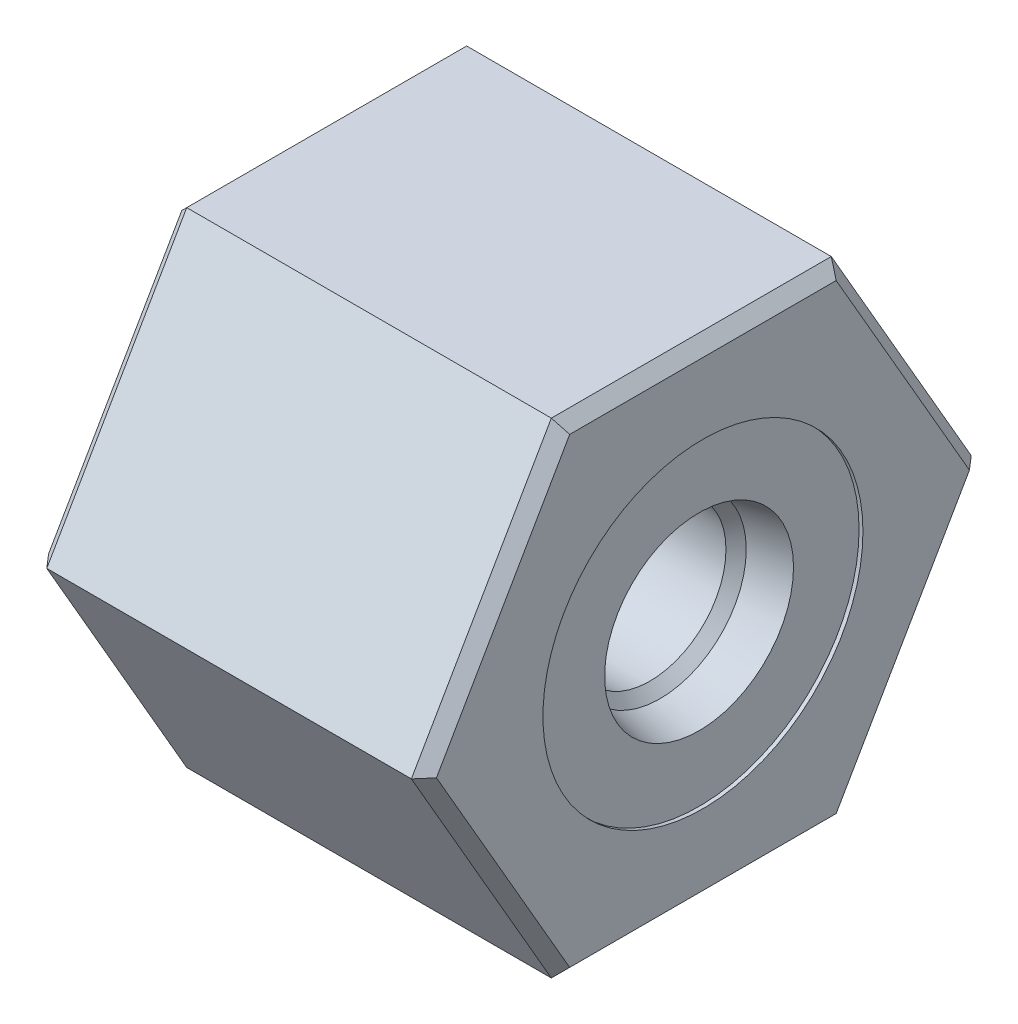
from build123d import *

# Parameters (mm, degrees)
EXTRUDE1_DEPTH = 25.4
CHAMFER1_SIZE  = 0.254
CHAMFER2_SIZE  = 0.762
CHAMFER3_SIZE  = 0.762
CHAMFER4_SIZE  = 0.762


with BuildPart() as part:
    # Sketch1 → Extrude1 (new body)
    with BuildSketch(Plane(origin=(0, 0, 0), x_dir=(0, -1, 0), z_dir=(-1, 0, 0))):
        Polygon((15.875, 9.165435523), (0, 18.330871047), (-15.875, 9.165435523), (-15.875, -9.165435523), (0, -18.330871047), (15.875, -9.165435523), align=None)
    extrude(amount=-EXTRUDE1_DEPTH)

    # Sketch2 → Cut-Revolve1 (revolve, cut)
    with BuildSketch(Plane.XY, mode=Mode.PRIVATE) as cut_revolve1_sk:
        with BuildLine():
            Line((0, 11.8872), (0, 0))
            Line((0, 0), (25.4, 0))
            Line((25.4, 0), (25.4, 10.4775))
            Line((25.4, 10.4775), (25.146, 10.4775))
            Line((25.146, 10.4775), (25.146, 6.1849))
            Line((25.146, 6.1849), (22.5933, 5.642306865))
            Line((22.5933, 5.642306865), (21.929393135, 4.9784))
            Line((21.929393135, 4.9784), (13.462, 4.9784))
            Line((13.462, 4.9784), (13.462, 11.7221))
            Line((13.462, 11.7221), (10.16, 11.7221))
            ThreePointArc((10.16, 11.7221), (9.989969941, 11.844096333), (9.785188594, 11.8872))
            Line((9.785188594, 11.8872), (0, 11.8872))
        make_face()
    revolve(cut_revolve1_sk.sketch.rotate(Axis((0, 0, 0), (1, 0, 0)), 270), axis=Axis((0, 0, 0), (1, 0, 0)), mode=Mode.SUBTRACT)  # turned: the seam where the file's is

    # Chamfer1
    chamfer1_edges = [part.edges().sort_by_distance(p)[0] for p in [
        (0, 0, 11.8872),
    ]]
    chamfer(chamfer1_edges, length=CHAMFER1_SIZE)

    # Chamfer2
    chamfer2_edges = [part.edges().sort_by_distance(p)[0] for p in [
        (13.462, 0, 4.9784),
    ]]
    chamfer(chamfer2_edges, length=CHAMFER2_SIZE)

    # Chamfer3
    chamfer3_edges = [part.edges().sort_by_distance(p)[0] for p in [
        (0, -7.9375, -13.748153285),
        (0, 7.9375, -13.748153285),
        (0, 15.875, 0),
        (0, 7.9375, 13.748153285),
        (0, -7.9375, 13.748153285),
        (0, -15.875, 0),
    ]]
    chamfer(chamfer3_edges, length=CHAMFER3_SIZE)

    # Chamfer4
    chamfer4_edges = [part.edges().sort_by_distance(p)[0] for p in [
        (25.4, 7.9375, 13.748153285),
        (25.4, 15.875, 0),
        (25.4, 7.9375, -13.748153285),
        (25.4, -7.9375, -13.748153285),
        (25.4, -15.875, 0),
        (25.4, -7.9375, 13.748153285),
    ]]
    chamfer(chamfer4_edges, length=CHAMFER4_SIZE)


solid = part.part
